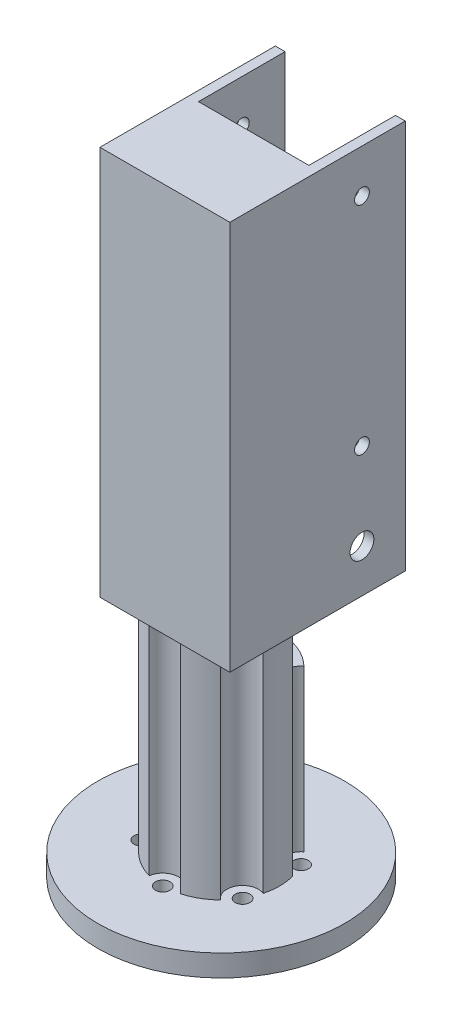
from build123d import *

# Parameters (mm, degrees)
SKETCH_1_R          = 28.5
SKETCH_1_R_2        = 1.7
EXTRUDE_1_DEPTH     = 5
SKETCH_2_R          = 13.5
EXTRUDE_2_DEPTH     = 50
SKETCH_3_R          = 3.65
CUT_EXTRUDE_1_DEPTH = 50
SKETCH_4_W          = 30
SKETCH_4_H          = 55
EXTRUDE_3_DEPTH     = 90
SKETCH_6_R          = 1.7
SKETCH_6_R_2        = 2.75
CUT_EXTRUDE_2_DEPTH = 50
SKETCH_7_W          = 25.5
SKETCH_7_H          = 110.843536678
CUT_EXTRUDE_3_DEPTH = 20
SKETCH_8_W          = 36.70966092
SKETCH_8_H          = 18.654828845
CUT_EXTRUDE_4_DEPTH = 110


with BuildPart() as part:
    # 草图1 → 凸台-拉伸1 (new body)
    with BuildSketch(Plane(origin=(0, 0, 0), x_dir=(1, 0, 0), z_dir=(0, 1, 0))):
        Circle(SKETCH_1_R)
        with Locations((0, 13.5)):
            Circle(SKETCH_1_R_2, mode=Mode.SUBTRACT)
        with Locations((11.691342951, 6.75)):
            Circle(SKETCH_1_R_2, mode=Mode.SUBTRACT)
        with Locations((11.691342951, -6.75)):
            Circle(SKETCH_1_R_2, mode=Mode.SUBTRACT)
        with Locations((0, -13.5)):
            Circle(SKETCH_1_R_2, mode=Mode.SUBTRACT)
        with Locations((-11.691342951, -6.75)):
            Circle(SKETCH_1_R_2, mode=Mode.SUBTRACT)
        with Locations((-11.691342951, 6.75)):
            Circle(SKETCH_1_R_2, mode=Mode.SUBTRACT)
    extrude(amount=EXTRUDE_1_DEPTH)

    # 草图2 → 凸台-拉伸2 (add)
    with BuildSketch(Plane(origin=(0, 5, 0), x_dir=(1, 0, 0), z_dir=(0, 1, 0))):
        Circle(SKETCH_2_R)
    extrude(amount=EXTRUDE_2_DEPTH)

    # 草图3 → 切除-拉伸1 (cut)
    with BuildSketch(Plane.XZ.offset(-5)):
        with Locations((-11.691342951, -6.75)):
            Circle(SKETCH_3_R)
        with Locations((-11.691342951, 6.75)):
            Circle(SKETCH_3_R)
        with Locations((0, 13.5)):
            Circle(SKETCH_3_R)
        with Locations((11.691342951, 6.75)):
            Circle(SKETCH_3_R)
        with Locations((11.691342951, -6.75)):
            Circle(SKETCH_3_R)
        with Locations((0, -13.5)):
            Circle(SKETCH_3_R)
    extrude(amount=-CUT_EXTRUDE_1_DEPTH, mode=Mode.SUBTRACT)

    # 草图4 → 凸台-拉伸3 (add)
    with BuildSketch(Plane(origin=(0, 55, 0), x_dir=(1, 0, 0), z_dir=(0, 1, 0))):
        Rectangle(SKETCH_4_W, SKETCH_4_H)
    extrude(amount=EXTRUDE_3_DEPTH)

    # 草图6 → 切除-拉伸2 (cut)
    with BuildSketch(Plane(origin=(15, 0, 0), x_dir=(0, 0, -1), z_dir=(1, 0, 0))):
        with Locations((17.5, 85)):
            Circle(SKETCH_6_R)
        with Locations((17.5, 135)):
            Circle(SKETCH_6_R)
        with Locations((17.5, 65)):
            Circle(SKETCH_6_R_2)
    extrude(amount=-CUT_EXTRUDE_2_DEPTH, mode=Mode.SUBTRACT)

    # 草图7 → 切除-拉伸3 (cut)
    with BuildSketch(Plane(origin=(0, 0, -27.5), x_dir=(-1, 0, 0), z_dir=(0, 0, -1))):
        with Locations((0, 97.565521138)):
            Rectangle(SKETCH_7_W, SKETCH_7_H)
    extrude(amount=-CUT_EXTRUDE_3_DEPTH, mode=Mode.SUBTRACT)

    # 草图8 → 切除-拉伸4 (cut)
    with BuildSketch(Plane.XZ.offset(-55)):
        with Locations((-1.438600971, 22.333988497)):
            Rectangle(SKETCH_8_W, SKETCH_8_H)
    extrude(amount=-CUT_EXTRUDE_4_DEPTH, mode=Mode.SUBTRACT)


solid = part.part
